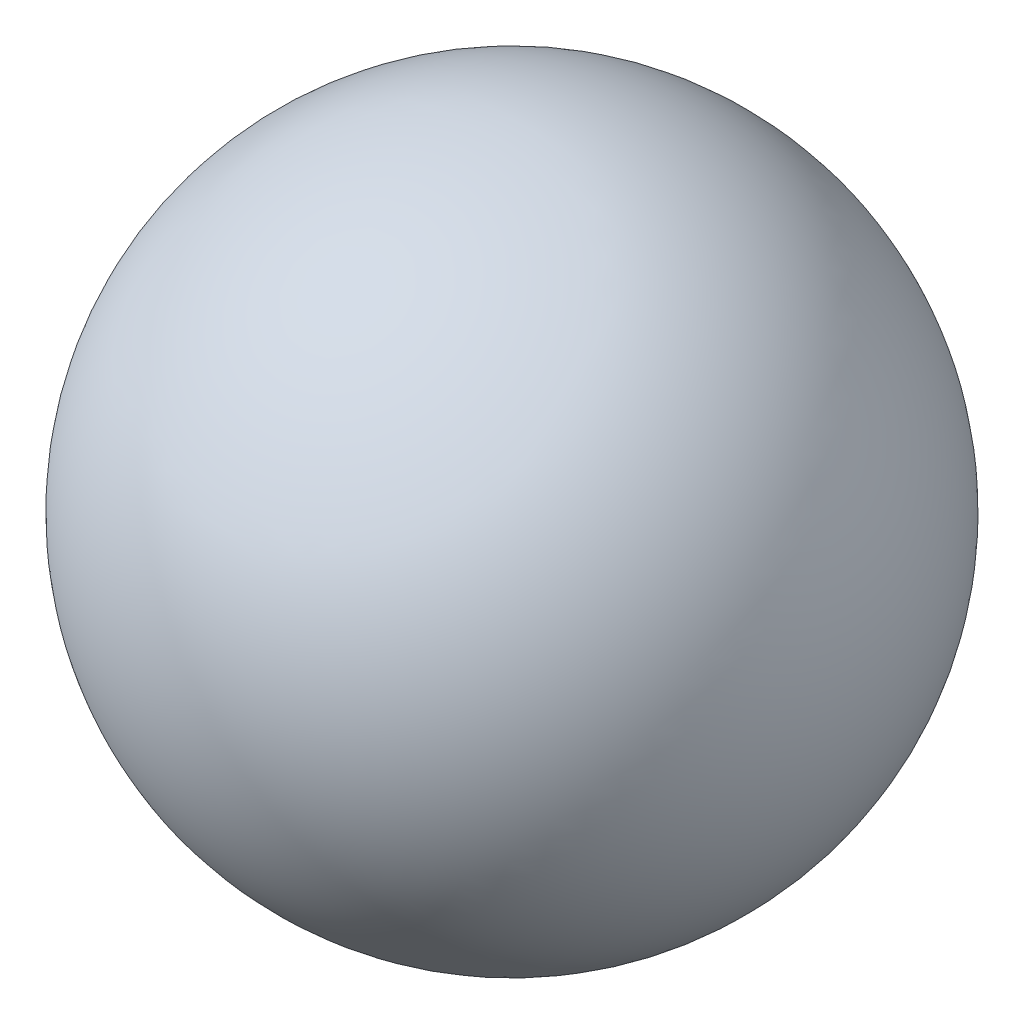
from build123d import *


with BuildPart() as part:
    # Sketch2 → Revolve1 (revolve)
    with BuildSketch(Plane(origin=(0, 0, 0), x_dir=(1, 0, 0), z_dir=(0, 1, 0))):
        with BuildLine():
            Line((0, 0), (0, 20))
            ThreePointArc((0, 20), (-20, 0), (0, -20))
            Line((0, -20), (0, 0))
        make_face()
    revolve(axis=Axis((0, 0, 0), (0, 0, 1)))


solid = part.part
